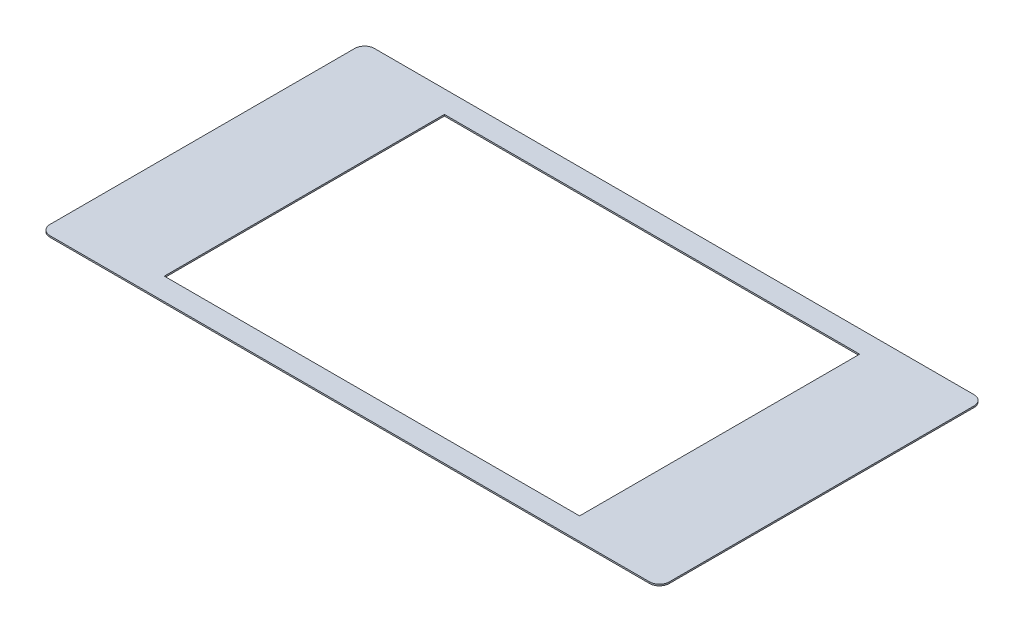
from build123d import *

# Parameters (mm, degrees)
SKETCH1_W           = 126
SKETCH1_H           = 66
SKETCH1_W_2         = 84.5
SKETCH1_H_2         = 57
BOSS_EXTRUDE1_DEPTH = 0.3
FILLET1_R           = 2


with BuildPart() as part:
    # Sketch1 → Boss-Extrude1 (new body)
    with BuildSketch(Plane.XZ.offset(34.5)):
        Rectangle(SKETCH1_W, SKETCH1_H)
        Rectangle(SKETCH1_W_2, SKETCH1_H_2, mode=Mode.SUBTRACT)
    extrude(amount=BOSS_EXTRUDE1_DEPTH)

    # Fillet1
    fillet1_edges = [part.edges().sort_by_distance(p)[0] for p in [
        (63, -34.65, -33),
        (-63, -34.65, -33),
        (-63, -34.65, 33),
        (63, -34.65, 33),
    ]]
    fillet(fillet1_edges, radius=FILLET1_R)


solid = part.part
